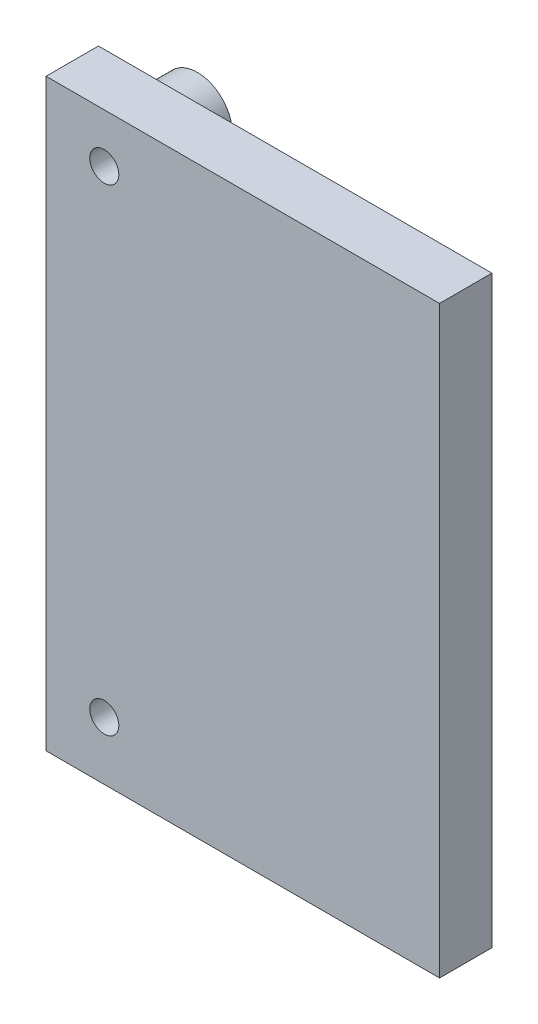
from build123d import *

# Parameters (mm, degrees)
ESQUISSE2_W            = 33.813849949
ESQUISSE2_H            = 50.207047895
BOSS_EXTRU_1_DEPTH     = 4.5
ESQUISSE6_W            = 26.70455913
ESQUISSE6_H            = 28.958
BOSS_EXTRU_ASICS_DEPTH = 1.5
ESQUISSE7_R            = 3
BOSS_EXTRU_FIXS_DEPTH  = 3.5
TROU_TARAUD_M31_D      = 2.5
TROU_TARAUD_M31_DEPTH  = 8


with BuildPart() as part:
    # Esquisse2 → Boss.-Extru.1 (new body)
    with BuildSketch(Plane.XY):
        with Locations((97.906924975, -94.896476053)):
            Rectangle(ESQUISSE2_W, ESQUISSE2_H)
    extrude(amount=BOSS_EXTRU_1_DEPTH)

    # Esquisse6 → Boss.-Extru. ASICs (add)
    with BuildSketch(Plane(origin=(0, 0, 0), x_dir=(-1, 0, 0), z_dir=(0, 0, -1))):
        with Locations((-98.850279565, -94.521)):
            Rectangle(ESQUISSE6_W, ESQUISSE6_H)
    extrude(amount=BOSS_EXTRU_ASICS_DEPTH)

    # Esquisse7 → Boss.-Extru. FIXs (add)
    with BuildSketch(Plane(origin=(0, 0, 0), x_dir=(-1, 0, 0), z_dir=(0, 0, -1))):
        with Locations((-86, -74)):
            Circle(ESQUISSE7_R)
        with Locations((-86, -115)):
            Circle(ESQUISSE7_R)
    extrude(amount=BOSS_EXTRU_FIXS_DEPTH)

    # Trou taraudé M31
    with Locations(Plane(origin=(0, 0, -3.5), x_dir=(-1, 0, 0), z_dir=(0, 0, -1))):
        with Locations((-86, -74), (-86, -115)):
            Hole(TROU_TARAUD_M31_D / 2, depth=TROU_TARAUD_M31_DEPTH)


solid = part.part
